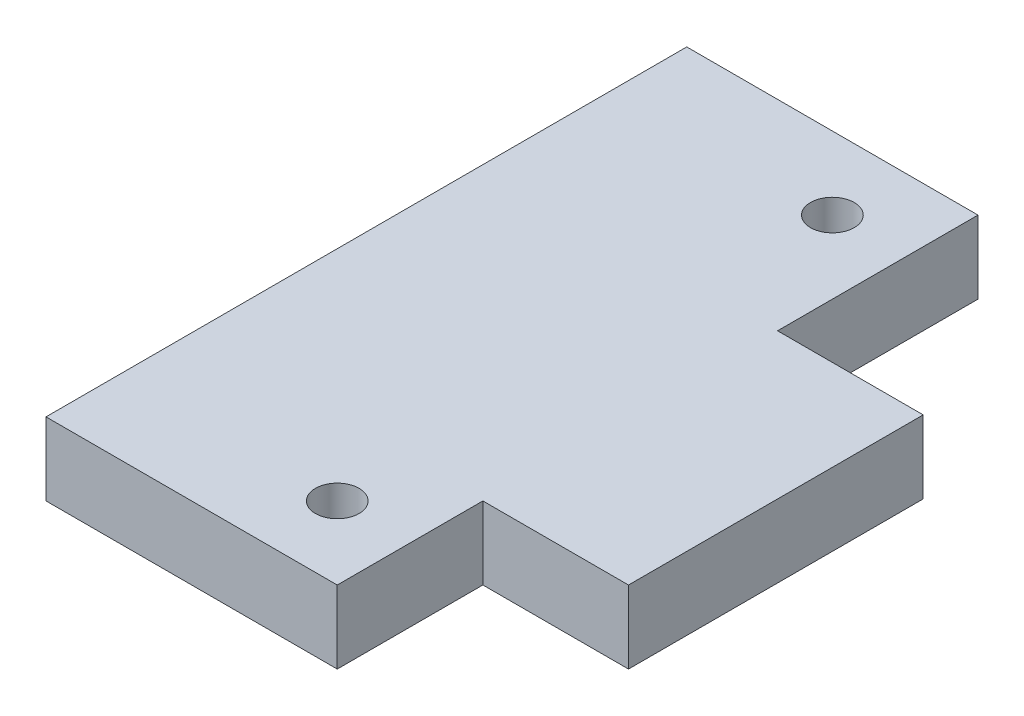
from build123d import *

# Parameters (mm, degrees)
SKETCH1_R           = 3
BOSS_EXTRUDE1_DEPTH = 10


with BuildPart() as part:
    # Sketch1 → Boss-Extrude1 (new body)
    with BuildSketch(Plane(origin=(0, 0, 0), x_dir=(1, 0, 0), z_dir=(0, 1, 0))):
        Polygon((40, 88), (40, 60.47283612), (60, 60.47283612), (60, 20), (40, 20), (40, 0), (0, 0), (0, 88), align=None)
        with Locations((30, 78)):
            Circle(SKETCH1_R, mode=Mode.SUBTRACT)
        with Locations((30, 10)):
            Circle(SKETCH1_R, mode=Mode.SUBTRACT)
    extrude(amount=BOSS_EXTRUDE1_DEPTH)


solid = part.part
